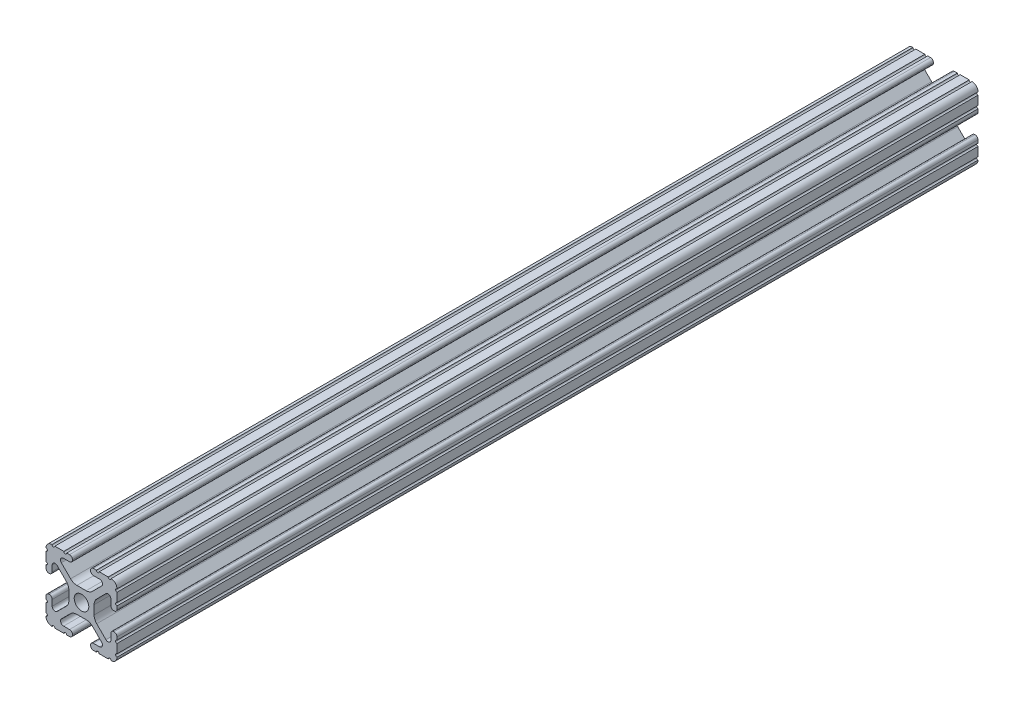
from build123d import *

# Parameters (mm, degrees)
SKETCH1_R           = 2.6035
BOSS_EXTRUDE1_DEPTH = 154


with BuildPart() as part:
    # Sketch1 → Boss-Extrude1 (new body, symmetric)
    with BuildSketch(Plane.XY):
        with BuildLine():
            Line((-7.179650497, -8.645192506), (-3.952270251, -5.423690499))
            ThreePointArc((-3.952270251, -5.423690499), (-2.922936451, -4.736929036), (-1.709253557, -4.4958))
            Line((-1.709253557, -4.4958), (1.709253557, -4.4958))
            ThreePointArc((1.709253557, -4.4958), (2.922936451, -4.736929036), (3.952270251, -5.423690499))
            Line((3.952270251, -5.423690499), (7.179650497, -8.645192506))
            ThreePointArc((7.179650497, -8.645192506), (7.41473083, -9.822813117), (6.416408329, -10.4902))
            Line((6.416408329, -10.4902), (4.287512407, -10.4902))
            ThreePointArc((4.287512407, -10.4902), (3.54574862, -10.79744862), (3.2385, -11.539212407))
            Line((3.2385, -11.539212407), (3.2385, -11.650987593))
            ThreePointArc((3.2385, -11.650987593), (3.54574862, -12.39275138), (4.287512407, -12.7))
            Line((4.287512407, -12.7), (5.317126718, -12.7))
            ThreePointArc((5.317126718, -12.7), (5.825126718, -12.192), (6.333126718, -12.7))
            Line((6.333126718, -12.7), (9.550443118, -12.7))
            ThreePointArc((9.550443118, -12.7), (10.058366869, -12.192000006), (10.566443095, -12.699847501))
            ThreePointArc((10.566443095, -12.699847501), (12.082537762, -12.08250727), (12.699846982, -10.566399977))
            ThreePointArc((12.699846982, -10.566399977), (12.192000006, -10.058323491), (12.7, -9.5504))
            Line((12.7, -9.5504), (12.7, -6.3330836))
            ThreePointArc((12.7, -6.3330836), (12.192, -5.8250836), (12.7, -5.3170836))
            Line((12.7, -5.3170836), (12.7, -4.287469289))
            ThreePointArc((12.7, -4.287469289), (12.39275138, -3.545705502), (11.650987593, -3.238456882))
            Line((11.650987593, -3.238456882), (11.539212407, -3.238456882))
            ThreePointArc((11.539212407, -3.238456882), (10.79744862, -3.545705502), (10.4902, -4.287469289))
            Line((10.4902, -4.287469289), (10.4902, -6.402089023))
            ThreePointArc((10.4902, -6.402089023), (9.856505071, -7.351067942), (8.737131347, -7.129408934))
            Line((8.737131347, -7.129408934), (5.441005833, -3.840816462))
            ThreePointArc((5.441005833, -3.840816462), (4.750877967, -2.809883091), (4.5085, -1.593185507))
            Line((4.5085, -1.593185507), (4.5085, 1.593185507))
            ThreePointArc((4.5085, 1.593185507), (4.750877967, 2.809883091), (5.441005833, 3.840816462))
            Line((5.441005833, 3.840816462), (8.737131347, 7.129408934))
            ThreePointArc((8.737131347, 7.129408934), (9.856505071, 7.351067942), (10.4902, 6.402089023))
            Line((10.4902, 6.402089023), (10.4902, 4.287469289))
            ThreePointArc((10.4902, 4.287469289), (10.79744862, 3.545705502), (11.539212407, 3.238456882))
            Line((11.539212407, 3.238456882), (11.650987593, 3.238456882))
            ThreePointArc((11.650987593, 3.238456882), (12.39275138, 3.545705502), (12.7, 4.287469289))
            Line((12.7, 4.287469289), (12.7, 5.3170836))
            ThreePointArc((12.7, 5.3170836), (12.192, 5.8250836), (12.7, 6.3330836))
            Line((12.7, 6.3330836), (12.7, 9.5504))
            ThreePointArc((12.7, 9.5504), (12.192000006, 10.058323491), (12.699846982, 10.566399977))
            ThreePointArc((12.699846982, 10.566399977), (12.082537762, 12.08250727), (10.566443095, 12.699847501))
            ThreePointArc((10.566443095, 12.699847501), (10.058366869, 12.192000006), (9.550443118, 12.7))
            Line((9.550443118, 12.7), (6.333126718, 12.7))
            ThreePointArc((6.333126718, 12.7), (5.825126718, 12.192), (5.317126718, 12.7))
            Line((5.317126718, 12.7), (4.287512407, 12.7))
            ThreePointArc((4.287512407, 12.7), (3.54574862, 12.39275138), (3.2385, 11.650987593))
            Line((3.2385, 11.650987593), (3.2385, 11.539212407))
            ThreePointArc((3.2385, 11.539212407), (3.54574862, 10.79744862), (4.287512407, 10.4902))
            Line((4.287512407, 10.4902), (6.476788598, 10.4902))
            ThreePointArc((6.476788598, 10.4902), (7.432222385, 9.85140422), (7.207036008, 8.724370562))
            Line((7.207036008, 8.724370562), (3.898272566, 5.423169045))
            ThreePointArc((3.898272566, 5.423169045), (2.869120213, 4.736787962), (1.655778399, 4.4958))
            Line((1.655778399, 4.4958), (-1.655778399, 4.4958))
            ThreePointArc((-1.655778399, 4.4958), (-2.869120213, 4.736787962), (-3.898272566, 5.423169045))
            Line((-3.898272566, 5.423169045), (-7.207036008, 8.724370562))
            ThreePointArc((-7.207036008, 8.724370562), (-7.432222385, 9.85140422), (-6.476788598, 10.4902))
            Line((-6.476788598, 10.4902), (-4.287512407, 10.4902))
            ThreePointArc((-4.287512407, 10.4902), (-3.54574862, 10.79744862), (-3.2385, 11.539212407))
            Line((-3.2385, 11.539212407), (-3.2385, 11.650987593))
            ThreePointArc((-3.2385, 11.650987593), (-3.54574862, 12.39275138), (-4.287512407, 12.7))
            Line((-4.287512407, 12.7), (-5.317126718, 12.7))
            ThreePointArc((-5.317126718, 12.7), (-5.825126718, 12.192), (-6.333126718, 12.7))
            Line((-6.333126718, 12.7), (-9.550443118, 12.7))
            ThreePointArc((-9.550443118, 12.7), (-10.058366869, 12.192000006), (-10.566443095, 12.699847501))
            ThreePointArc((-10.566443095, 12.699847501), (-12.082537762, 12.08250727), (-12.699846982, 10.566399977))
            ThreePointArc((-12.699846982, 10.566399977), (-12.192000006, 10.058323491), (-12.7, 9.5504))
            Line((-12.7, 9.5504), (-12.7, 6.3330836))
            ThreePointArc((-12.7, 6.3330836), (-12.192, 5.8250836), (-12.7, 5.3170836))
            Line((-12.7, 5.3170836), (-12.7, 4.287469289))
            ThreePointArc((-12.7, 4.287469289), (-12.39275138, 3.545705502), (-11.650987593, 3.238456882))
            Line((-11.650987593, 3.238456882), (-11.539212407, 3.238456882))
            ThreePointArc((-11.539212407, 3.238456882), (-10.79744862, 3.545705502), (-10.4902, 4.287469289))
            Line((-10.4902, 4.287469289), (-10.4902, 6.402089023))
            ThreePointArc((-10.4902, 6.402089023), (-9.856505071, 7.351067942), (-8.737131347, 7.129408934))
            Line((-8.737131347, 7.129408934), (-5.441005833, 3.840816462))
            ThreePointArc((-5.441005833, 3.840816462), (-4.750877967, 2.809883091), (-4.5085, 1.593185507))
            Line((-4.5085, 1.593185507), (-4.5085, -1.593185507))
            ThreePointArc((-4.5085, -1.593185507), (-4.750877967, -2.809883091), (-5.441005833, -3.840816462))
            Line((-5.441005833, -3.840816462), (-8.737131347, -7.129408934))
            ThreePointArc((-8.737131347, -7.129408934), (-9.856505071, -7.351067942), (-10.4902, -6.402089023))
            Line((-10.4902, -6.402089023), (-10.4902, -4.287469289))
            ThreePointArc((-10.4902, -4.287469289), (-10.79744862, -3.545705502), (-11.539212407, -3.238456882))
            Line((-11.539212407, -3.238456882), (-11.650987593, -3.238456882))
            ThreePointArc((-11.650987593, -3.238456882), (-12.39275138, -3.545705502), (-12.7, -4.287469289))
            Line((-12.7, -4.287469289), (-12.7, -5.3170836))
            ThreePointArc((-12.7, -5.3170836), (-12.192, -5.8250836), (-12.7, -6.3330836))
            Line((-12.7, -6.3330836), (-12.7, -9.5504))
            ThreePointArc((-12.7, -9.5504), (-12.192000006, -10.058323491), (-12.699846982, -10.566399977))
            ThreePointArc((-12.699846982, -10.566399977), (-12.082537762, -12.08250727), (-10.566443095, -12.699847501))
            ThreePointArc((-10.566443095, -12.699847501), (-10.058366869, -12.192000006), (-9.550443118, -12.7))
            Line((-9.550443118, -12.7), (-6.333126718, -12.7))
            ThreePointArc((-6.333126718, -12.7), (-5.825126718, -12.192), (-5.317126718, -12.7))
            Line((-5.317126718, -12.7), (-4.287512407, -12.7))
            ThreePointArc((-4.287512407, -12.7), (-3.54574862, -12.39275138), (-3.2385, -11.650987593))
            Line((-3.2385, -11.650987593), (-3.2385, -11.539212407))
            ThreePointArc((-3.2385, -11.539212407), (-3.54574862, -10.79744862), (-4.287512407, -10.4902))
            Line((-4.287512407, -10.4902), (-6.416408329, -10.4902))
            ThreePointArc((-6.416408329, -10.4902), (-7.41473083, -9.822813117), (-7.179650497, -8.645192506))
        make_face()
        Circle(SKETCH1_R, mode=Mode.SUBTRACT)
    extrude(amount=BOSS_EXTRUDE1_DEPTH, both=True)


solid = part.part
